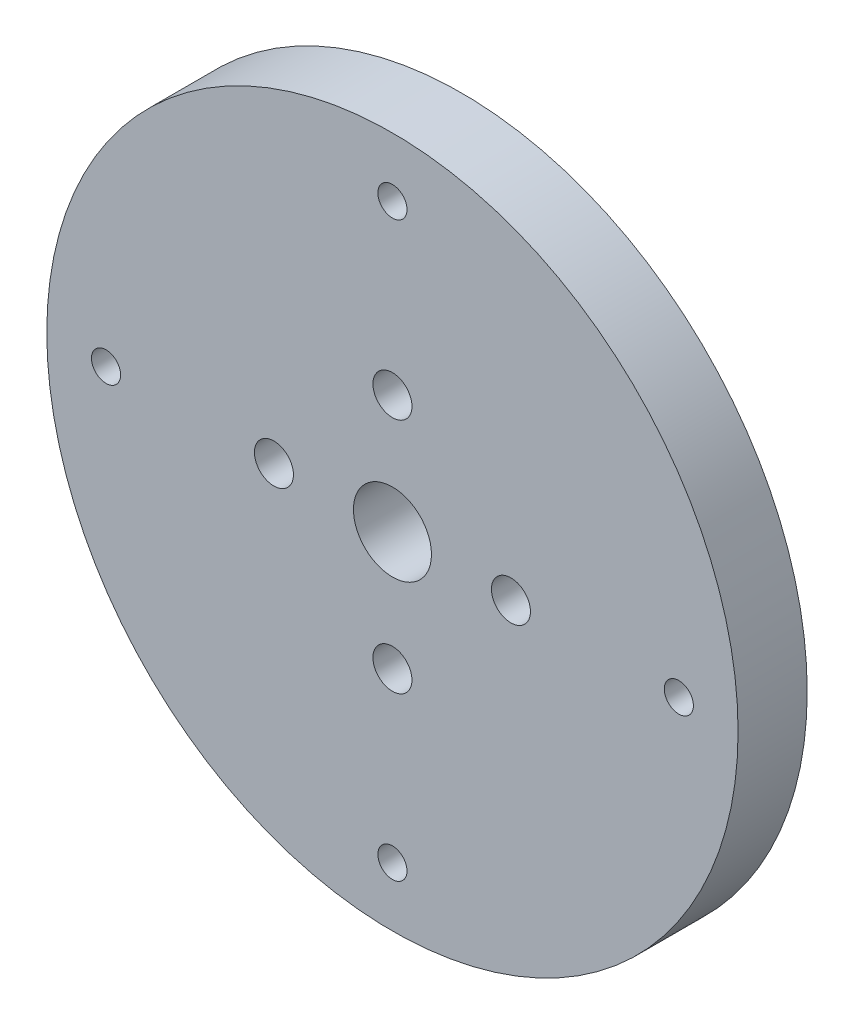
from build123d import *

# Parameters (mm, degrees)
SKETCH1_R           = 35
SKETCH1_R_2         = 3.95
SKETCH1_R_3         = 1.975
SKETCH1_R_4         = 1.475
BOSS_EXTRUDE1_DEPTH = 7


with BuildPart() as part:
    # Sketch1 → Boss-Extrude1 (new body)
    with BuildSketch(Plane.XY):
        Circle(SKETCH1_R)
        Circle(SKETCH1_R_2, mode=Mode.SUBTRACT)
        with Locations((0, 12)):
            Circle(SKETCH1_R_3, mode=Mode.SUBTRACT)
        with Locations((0, 29)):
            Circle(SKETCH1_R_4, mode=Mode.SUBTRACT)
        with Locations((29, 0)):
            Circle(SKETCH1_R_4, mode=Mode.SUBTRACT)
        with Locations((0, -29)):
            Circle(SKETCH1_R_4, mode=Mode.SUBTRACT)
        with Locations((-29, 0)):
            Circle(SKETCH1_R_4, mode=Mode.SUBTRACT)
        with Locations((12, 0)):
            Circle(SKETCH1_R_3, mode=Mode.SUBTRACT)
        with Locations((0, -12)):
            Circle(SKETCH1_R_3, mode=Mode.SUBTRACT)
        with Locations((-12, 0)):
            Circle(SKETCH1_R_3, mode=Mode.SUBTRACT)
    extrude(amount=BOSS_EXTRUDE1_DEPTH)


solid = part.part
